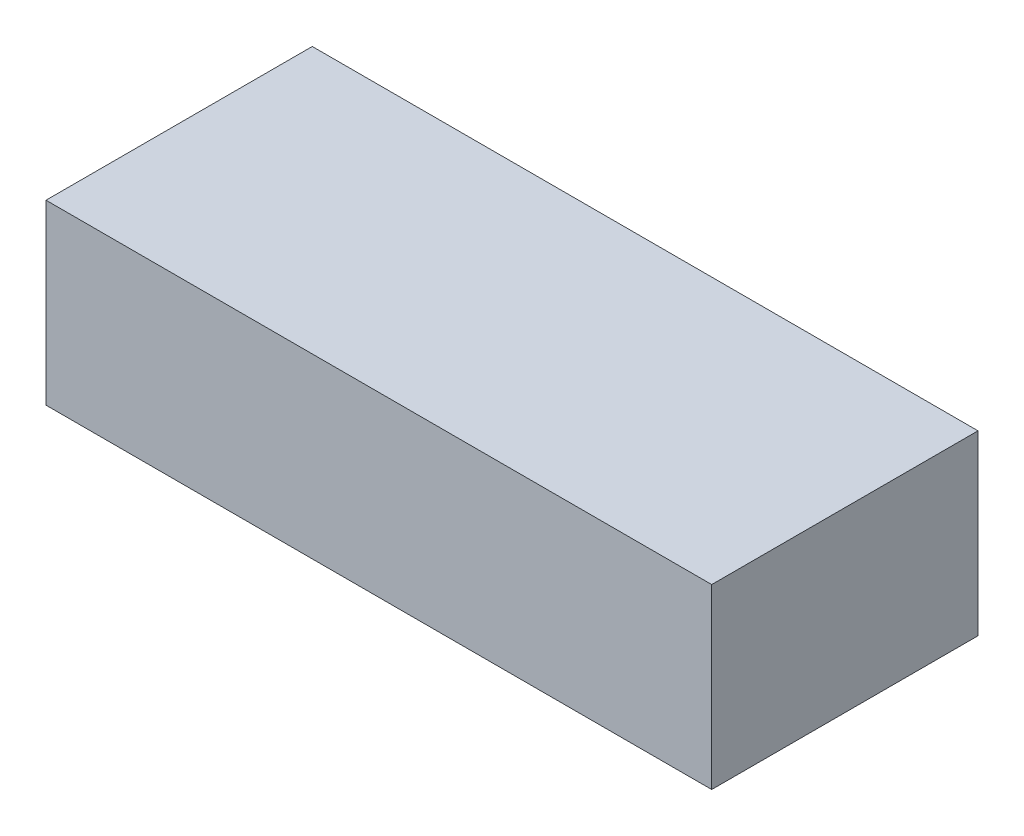
from build123d import *

# Parameters (mm, degrees)
SKETCH1_W           = 150
SKETCH1_H           = 60
BOSS_EXTRUDE1_DEPTH = 40


with BuildPart() as part:
    # Sketch1 → Boss-Extrude1 (new body)
    with BuildSketch(Plane(origin=(0, 0, 0), x_dir=(1, 0, 0), z_dir=(0, 1, 0))):
        with Locations((-75, -30)):
            Rectangle(SKETCH1_W, SKETCH1_H)
    extrude(amount=BOSS_EXTRUDE1_DEPTH)


solid = part.part
